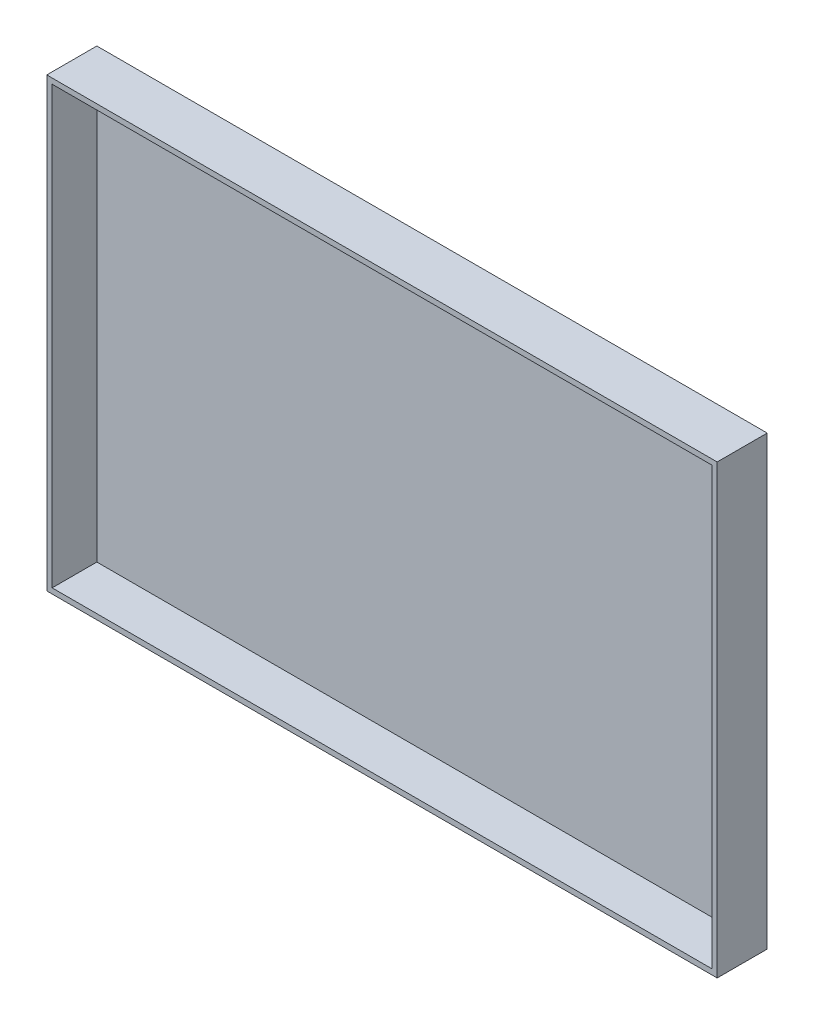
from build123d import *

# Parameters (mm, degrees)
CROQUIS1_W              = 150
CROQUIS1_H              = 100
SALIENTE_EXTRUIR1_DEPTH = 1.2
CROQUIS2_W              = 150
CROQUIS2_H              = 100
CROQUIS2_W_2            = 147.6
CROQUIS2_H_2            = 97.6
SALIENTE_EXTRUIR2_DEPTH = 10


with BuildPart() as part:
    # Croquis1 → Saliente-Extruir1 (new body)
    with BuildSketch(Plane.XY):
        with Locations((-111.396374911, 16.428571429)):
            Rectangle(CROQUIS1_W, CROQUIS1_H)
    extrude(amount=SALIENTE_EXTRUIR1_DEPTH)

    # Croquis2 → Saliente-Extruir2 (add)
    with BuildSketch(Plane.XY.offset(1.2)):
        with Locations((-111.396374911, 16.428571429)):
            Rectangle(CROQUIS2_W, CROQUIS2_H)
        with Locations((-111.396374911, 16.428571429)):
            Rectangle(CROQUIS2_W_2, CROQUIS2_H_2, mode=Mode.SUBTRACT)
    extrude(amount=SALIENTE_EXTRUIR2_DEPTH)


solid = part.part
